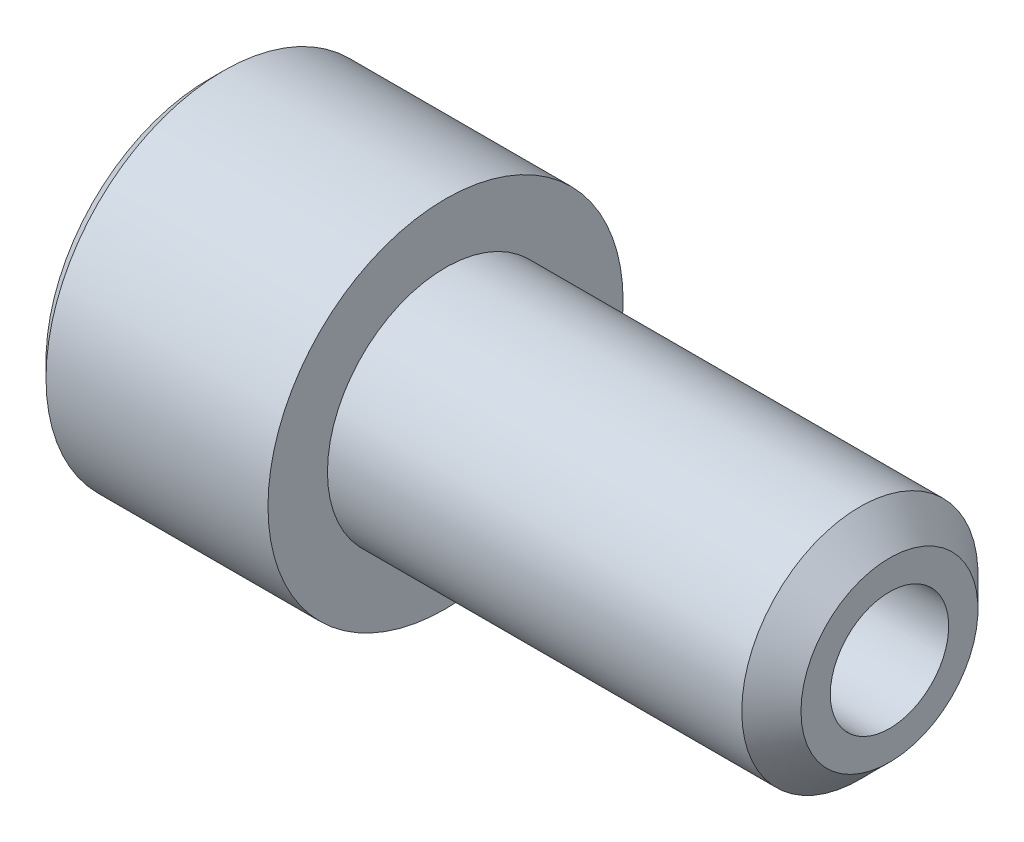
from build123d import *

# Parameters (mm, degrees)
CHAMFER1_SIZE      = 2
CHAMFER2_SIZE      = 1
CUT_EXTRUDE1_DEPTH = 8
CHAMFER3_SIZE      = 1
SKETCH4_R          = 4
CUT_EXTRUDE2_DEPTH = 39


with BuildPart() as part:
    # Sketch1 → Revolve1 (revolve)
    with BuildSketch(Plane.XY):
        Polygon((0, 0), (0, 12), (16, 12), (16, 7.981), (46, 7.981), (46, 0), align=None)
    revolve(axis=Axis((-88.705490849, 0, 0), (1, 0, 0)))

    # Chamfer1
    chamfer1_edges = [part.edges().sort_by_distance(p)[0] for p in [
        (46, -7.981, 0),
    ]]
    chamfer(chamfer1_edges, length=CHAMFER1_SIZE)

    # Chamfer2
    chamfer2_edges = [part.edges().sort_by_distance(p)[0] for p in [
        (0, -12, 0),
    ]]
    chamfer(chamfer2_edges, length=CHAMFER2_SIZE)

    # Sketch3 → Cut-Extrude1 (cut)
    with BuildSketch(Plane(origin=(0, 0, 0), x_dir=(0, 0, -1), z_dir=(1, 0, 0))):
        Polygon((-8.082903769, 0), (-4.041451884, -7), (4.041451884, -7), (8.082903769, 0), (4.041451884, 7), (-4.041451884, 7), align=None)
    extrude(amount=CUT_EXTRUDE1_DEPTH, mode=Mode.SUBTRACT)

    # Chamfer3
    chamfer3_edges = [part.edges().sort_by_distance(p)[0] for p in [
        (0, 3.5, 6.062177826),
        (0, -3.5, 6.062177826),
        (0, -7, 0),
        (0, -3.5, -6.062177826),
        (0, 3.5, -6.062177826),
        (0, 7, 0),
    ]]
    chamfer(chamfer3_edges, length=CHAMFER3_SIZE)

    # Sketch4 → Cut-Extrude2 (cut, through all)
    with BuildSketch(Plane.ZY.offset(-8)):
        Circle(SKETCH4_R)
    extrude(amount=-CUT_EXTRUDE2_DEPTH, mode=Mode.SUBTRACT)


solid = part.part
